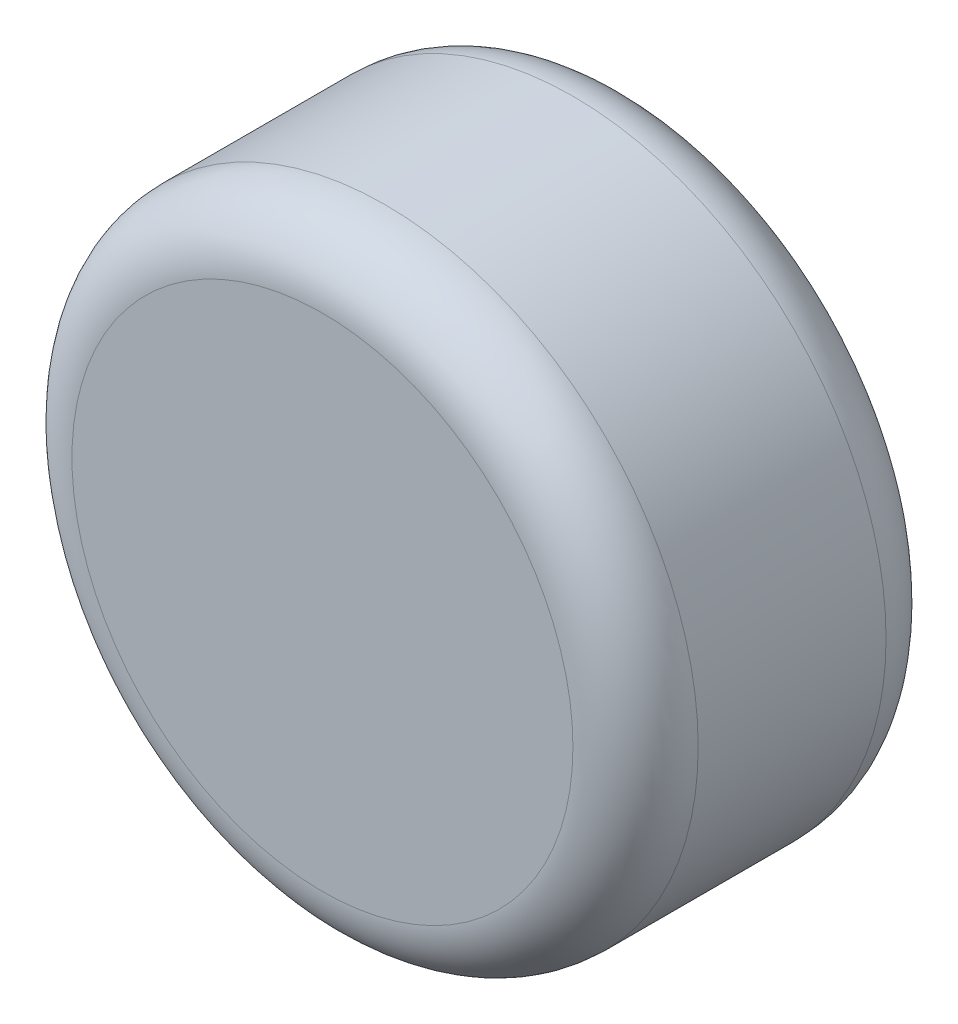
from build123d import *

# Parameters (mm, degrees)
SKETCH_2_R      = 50
EXTRUDE_2_DEPTH = 50
FILLET_1_R      = 10


with BuildPart() as part:
    # ｽｹｯﾁ2 → ﾎﾞｽ - 押し出し2 (new body)
    with BuildSketch(Plane.XY):
        Circle(SKETCH_2_R)
    extrude(amount=EXTRUDE_2_DEPTH)

    # ﾌｨﾚｯﾄ1
    fillet_1_edges = [part.edges().sort_by_distance(p)[0] for p in [
        (-50, 0, 0),
        (-50, 0, 50),
    ]]
    fillet(fillet_1_edges, radius=FILLET_1_R)


solid = part.part
